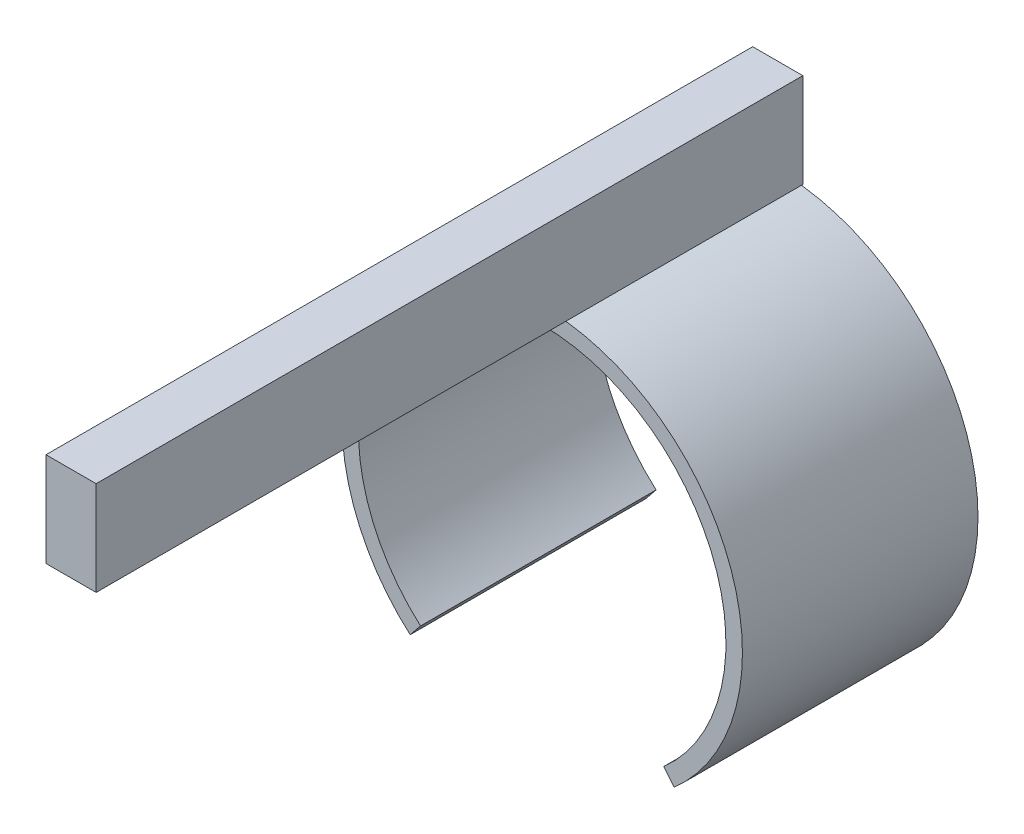
from build123d import *

# Parameters (mm, degrees)
SKETCH1_R           = 4.25
SKETCH1_R_2         = 3.9
BOSS_EXTRUDE1_DEPTH = 5
CUT_EXTRUDE4_DEPTH  = 5
SKETCH3_W           = 1.064141482
SKETCH3_H           = 5
BOSS_EXTRUDE2_DEPTH = 2
SKETCH4_W           = 1.064141482
SKETCH4_H           = 2
BOSS_EXTRUDE3_DEPTH = 10


with BuildPart() as part:
    # Sketch1 → Boss-Extrude1 (new body)
    with BuildSketch(Plane.XY):
        Circle(SKETCH1_R)
        Circle(SKETCH1_R_2, mode=Mode.SUBTRACT)
    extrude(amount=BOSS_EXTRUDE1_DEPTH)

    # Sketch2 → Cut-Extrude4 (cut)
    with BuildSketch(Plane.XY.offset(5)):
        with BuildLine():
            Line((-0.002204063, 0.259753333), (-3.852557283, -4.489569771))
            ThreePointArc((-3.852557283, -4.489569771), (-2.297684013, -6.180995378), (-0.002204063, -6.277552461))
            ThreePointArc((-0.002204063, -6.277552461), (2.293275887, -6.180995378), (3.848149157, -4.489569771))
            Line((3.848149157, -4.489569771), (-0.002204063, 0.259753333))
        make_face()
    extrude(amount=-CUT_EXTRUDE4_DEPTH, mode=Mode.SUBTRACT)


with BuildPart() as body_2:
    # Sketch3 → Boss-Extrude2 (new body)
    with BuildSketch(Plane(origin=(0, 4.25, 0), x_dir=(1, 0, 0), z_dir=(0, 1, 0))):
        with Locations((0, -2.5)):
            Rectangle(SKETCH3_W, SKETCH3_H)
    extrude(amount=BOSS_EXTRUDE2_DEPTH)

    # Sketch4 → Boss-Extrude3 (add)
    with BuildSketch(Plane.XY.offset(5)):
        with Locations((0, 5.25)):
            Rectangle(SKETCH4_W, SKETCH4_H)
    extrude(amount=BOSS_EXTRUDE3_DEPTH)


solid = Compound([part.part, body_2.part])
